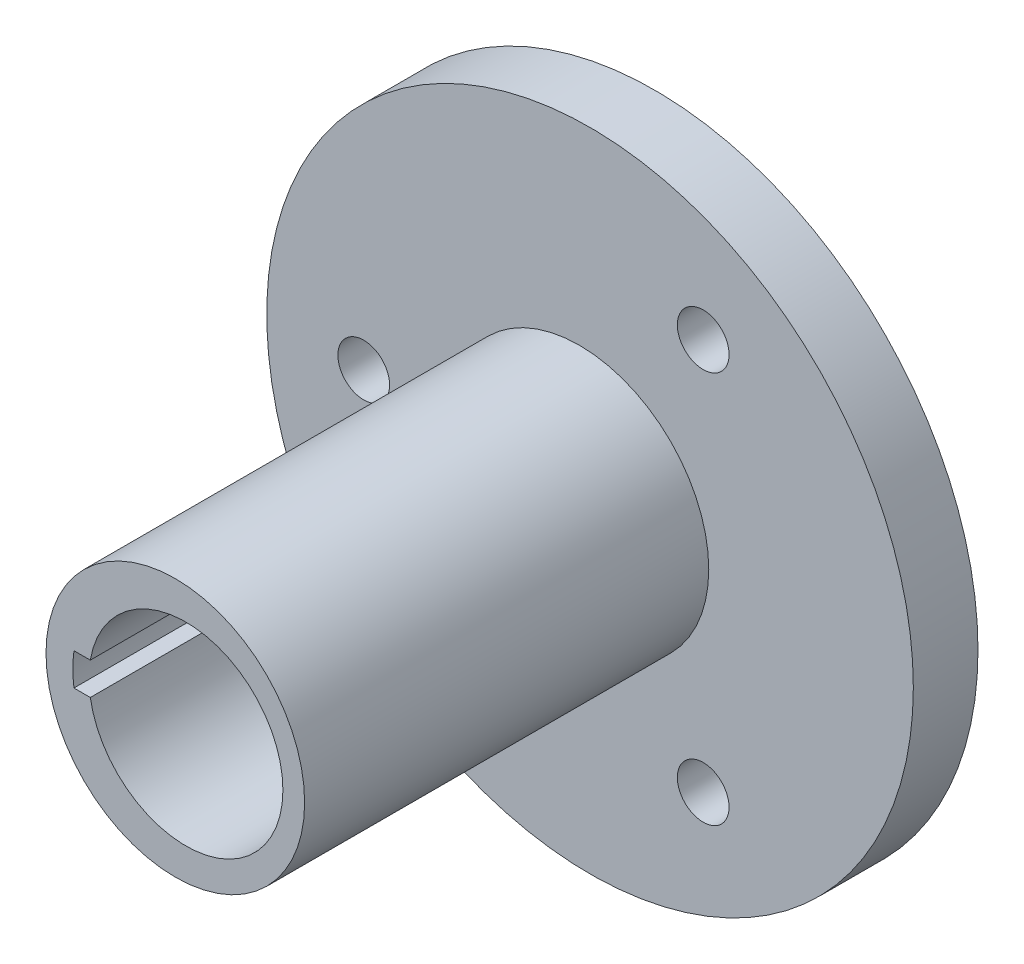
from build123d import *

# Parameters (mm, degrees)
SKETCH1_R               = 50
BOSS_EXTRUDE1_DEPTH     = 10
SKETCH1_3_R             = 4
CUT_EXTRUDE1_DEPTH      = 10
SKETCH1_4_R             = 20
BOSS_EXTRUDE2_DEPTH     = 62.5
CUT_EXTRUDE3_DEPTH      = 95.372930441
CUT_EXTRUDE3_DEPTH_BACK = 95.372930441
SKETCH3_R               = 6.5


with BuildPart() as part:
    # Sketch1 → Boss-Extrude1 (new body)
    with BuildSketch(Plane.XY):
        Circle(SKETCH1_R)
    extrude(amount=-BOSS_EXTRUDE1_DEPTH)

    # Sketch1_3 → Cut-Extrude1 (cut)
    with BuildSketch(Plane.XY):
        with Locations((-35, 0)):
            Circle(SKETCH1_3_R)
        with Locations((17.5, 30.310889132)):
            Circle(SKETCH1_3_R)
        with Locations((17.5, -30.310889132)):
            Circle(SKETCH1_3_R)
    extrude(amount=-CUT_EXTRUDE1_DEPTH, mode=Mode.SUBTRACT)

    # Sketch1_4 → Boss-Extrude2 (add)
    with BuildSketch(Plane.XY):
        with Locations((-1.640921825, 0)):
            Circle(SKETCH1_4_R)
        with BuildLine():
            Line((-17.320508076, 2.5), (-14.790199458, 2.5))
            ThreePointArc((-14.790199458, 2.5), (15, 0), (-14.790199458, -2.5))
            Line((-14.790199458, -2.5), (-17.320508076, -2.5))
            ThreePointArc((-17.320508076, -2.5), (-17.5, 0), (-17.320508076, 2.5))
        make_face(mode=Mode.SUBTRACT)
    extrude(amount=BOSS_EXTRUDE2_DEPTH)

    # Sketch3 → Cut-Extrude3 (cut, two sides: drawn at the far end of the back side and taken through both)
    with BuildSketch(Plane.XY.offset(-CUT_EXTRUDE3_DEPTH_BACK)):
        Circle(SKETCH3_R)
    extrude(amount=CUT_EXTRUDE3_DEPTH + CUT_EXTRUDE3_DEPTH_BACK, mode=Mode.SUBTRACT)


solid = part.part
